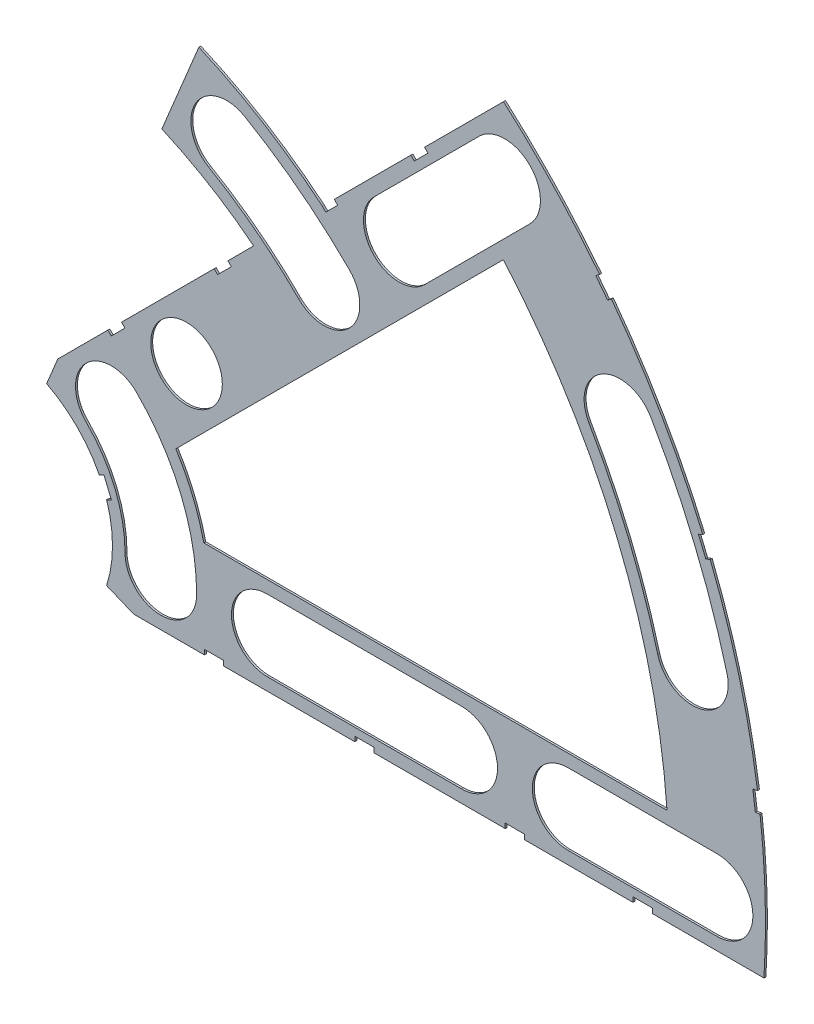
from build123d import *

# Parameters (mm, degrees)
BOSS_EXTRUDE1_DEPTH = 0.254
SKETCH2_R           = 4.699
CUT_EXTRUDE1_DEPTH  = 1.254
SKETCH3_W           = 2.54
SKETCH3_H           = 0.635
CUT_EXTRUDE2_DEPTH  = 1.254
CUT_EXTRUDE3_DEPTH  = 1.254


with BuildPart() as part:
    # Sketch1 → Boss-Extrude1 (new body)
    with BuildSketch(Plane.XY):
        with BuildLine():
            Line((27.218819563, 62.393373411), (22.357699804, 50.65759216))
            ThreePointArc((22.357699804, 50.65759216), (28.61353693, 47.405947816), (34.405475059, 43.38573118))
            Line((34.405475059, 43.38573118), (8.696654013, 17.676910134))
            Line((8.696654013, 17.676910134), (7.228954972, 14.133571205))
            ThreePointArc((7.228954972, 14.133571205), (14.666587579, 6.075099489), (15.105587123, -4.88230096))
            Line((15.105587123, -4.88230096), (18.648926052, -6.35))
            Line((18.648926052, -6.35), (101.401368334, -6.35))
            ThreePointArc((101.401368334, -6.35), (93.866160503, 38.880636728), (67.21146711, 76.191723231))
            Line((67.21146711, 76.191723231), (43.43415954, 52.414415661))
            ThreePointArc((43.43415954, 52.414415661), (35.677104191, 57.973626939), (27.218819563, 62.393373411))
        make_face()
        with BuildLine():
            Line((88.672924278, 6.35), (27.86051193, 6.35))
            ThreePointArc((27.86051193, 6.35), (26.399857642, 10.93517908), (24.190484974, 15.210228852))
            Line((24.190484974, 15.210228852), (67.191354125, 58.211098004))
            ThreePointArc((67.191354125, 58.211098004), (82.13289044, 34.020557137), (88.672924278, 6.35))
        make_face(mode=Mode.SUBTRACT)
    extrude(amount=BOSS_EXTRUDE1_DEPTH)

    # Sketch2 → Cut-Extrude1 (cut, through all)
    with BuildSketch(Plane.XY.offset(0.254)):
        with Locations((22.225, 0)):
            Circle(SKETCH2_R)
        with Locations((36.195, 0)):
            Circle(SKETCH2_R)
        with Locations((61.722, 0)):
            Circle(SKETCH2_R)
        with Locations((75.692, 0)):
            Circle(SKETCH2_R)
        with Locations((95.25, 0)):
            Circle(SKETCH2_R)
        with Locations((15.715448212, 15.715448212)):
            Circle(SKETCH2_R)
        with Locations((25.593729945, 25.593729945)):
            Circle(SKETCH2_R)
        with Locations((43.644044748, 43.644044748)):
            Circle(SKETCH2_R)
        with Locations((53.522326482, 53.522326482)):
            Circle(SKETCH2_R)
        with Locations((92.004434954, 24.652514046)):
            Circle(SKETCH2_R)
        with Locations((82.48891971, 47.625)):
            Circle(SKETCH2_R)
        with Locations((67.351920908, 67.351920908)):
            Circle(SKETCH2_R)
        with Locations((30.861, 53.452819972)):
            Circle(SKETCH2_R)
    extrude(amount=-CUT_EXTRUDE1_DEPTH, mode=Mode.SUBTRACT)

    # Sketch3 → Cut-Extrude2 (cut, through all)
    with BuildSketch(Plane.XY.offset(0.254)):
        Polygon((15.266435406, 24.246691527), (17.06248663, 26.042742751), (17.511499436, 25.593729945), (15.715448212, 23.797678721), align=None)
        Polygon((43.43415954, 52.414415661), (44.991083167, 53.971339288), (45.440095973, 53.522326482), (43.883172346, 51.965402855), align=None)
        with Locations((29.21, -6.0325)):
            Rectangle(SKETCH3_W, SKETCH3_H)
        with Locations((68.707, -6.0325)):
            Rectangle(SKETCH3_W, SKETCH3_H)
        Polygon((29.230733674, 38.210989795), (31.026784898, 40.007041019), (31.475797704, 39.558028213), (29.67974648, 37.761976989), align=None)
        Polygon((56.845021246, 65.825277367), (55.048970022, 64.029226143), (55.497982828, 63.580213337), (57.294034052, 65.376264561), align=None)
        with Locations((48.9585, -6.0325)):
            Rectangle(SKETCH3_W, SKETCH3_H)
        with Locations((85.471, -6.0325)):
            Rectangle(SKETCH3_W, SKETCH3_H)
        Polygon((99.935462164, 14.437711971), (100.266998693, 11.919442024), (101.526133667, 12.085210288), (101.194597138, 14.603480236), align=None)
        Polygon((93.765504959, 37.464305742), (94.938831965, 37.950313702), (93.966816047, 40.296967714), (92.793489041, 39.810959755), align=None)
        Polygon((79.327792988, 62.471156422), (80.874047017, 60.456038938), (81.88160576, 61.229165953), (80.33535173, 63.244283437), align=None)
        Polygon((13.593916116, 7.005422516), (14.565932035, 4.658768503), (15.739259041, 5.144776462), (14.767243123, 7.491430475), align=None)
    extrude(amount=-CUT_EXTRUDE2_DEPTH, mode=Mode.SUBTRACT)

    # Sketch7 → Cut-Extrude3 (cut, through all)
    with BuildSketch(Plane.XY.offset(0.254)):
        with BuildLine():
            Line((36.195, 4.699), (61.722, 4.699))
            ThreePointArc((61.722, 4.699), (66.421, 0), (61.722, -4.699))
            Line((61.722, -4.699), (36.195, -4.699))
            ThreePointArc((36.195, -4.699), (31.496, 0), (36.195, 4.699))
        make_face()
        with BuildLine():
            Line((75.692, 4.699), (95.25, 4.699))
            ThreePointArc((95.25, 4.699), (99.949, 0), (95.25, -4.699))
            Line((95.25, -4.699), (75.692, -4.699))
            ThreePointArc((75.692, -4.699), (70.993, 0), (75.692, 4.699))
        make_face()
        with BuildLine():
            Line((50.199631717, 56.845021246), (64.029226143, 70.674615673))
            ThreePointArc((64.029226143, 70.674615673), (70.674615673, 70.674615673), (70.674615673, 64.029226143))
            Line((70.674615673, 64.029226143), (56.845021246, 50.199631717))
            ThreePointArc((56.845021246, 50.199631717), (50.199631717, 50.199631717), (50.199631717, 56.845021246))
        make_face()
        with BuildLine():
            ThreePointArc((46.966739513, 46.966739513), (40.434542876, 52.695322215), (33.2105, 57.522273345))
            ThreePointArc((33.2105, 57.522273345), (26.791546628, 55.802319972), (28.5115, 49.3833666))
            ThreePointArc((28.5115, 49.3833666), (34.713402966, 45.239387523), (40.321349984, 40.321349984))
            ThreePointArc((40.321349984, 40.321349984), (46.966739513, 40.321349984), (46.966739513, 46.966739513))
        make_face()
        with BuildLine():
            ThreePointArc((26.924, 0), (24.874532533, 10.303368733), (19.038142977, 19.038142977))
            ThreePointArc((19.038142977, 19.038142977), (12.392753447, 19.038142977), (12.392753447, 12.392753447))
            ThreePointArc((12.392753447, 12.392753447), (16.191912687, 6.706909836), (17.526, 0))
            ThreePointArc((17.526, 0), (22.225, -4.699), (26.924, 0))
        make_face()
        with BuildLine():
            ThreePointArc((96.543320412, 25.868704739), (92.340835395, 38.248826381), (86.558373083, 49.9745))
            ThreePointArc((86.558373083, 49.9745), (80.13941971, 51.694453372), (78.419466338, 45.2755))
            ThreePointArc((78.419466338, 45.2755), (83.658215548, 34.652367484), (87.465549496, 23.436323353))
            ThreePointArc((87.465549496, 23.436323353), (93.220625647, 20.113628588), (96.543320412, 25.868704739))
        make_face()
    extrude(amount=-CUT_EXTRUDE3_DEPTH, mode=Mode.SUBTRACT)


solid = part.part
